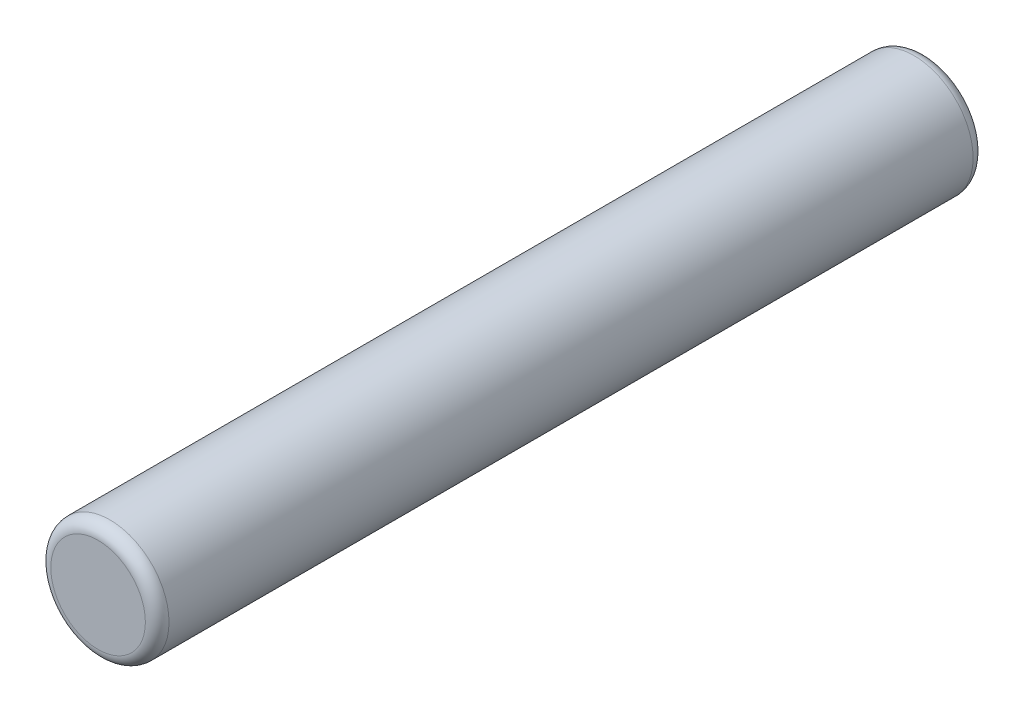
from build123d import *

# Parameters (mm, degrees)
SKETCH1_R           = 5
BOSS_EXTRUDE1_DEPTH = 35
FILLET1_R           = 1


with BuildPart() as part:
    # Sketch1 → Boss-Extrude1 (new body, symmetric)
    with BuildSketch(Plane.XY):
        Circle(SKETCH1_R)
    extrude(amount=BOSS_EXTRUDE1_DEPTH, both=True)

    # Fillet1
    fillet1_edges = [part.edges().sort_by_distance(p)[0] for p in [
        (-5, 0, -35),
        (-5, 0, 35),
    ]]
    fillet(fillet1_edges, radius=FILLET1_R)


solid = part.part
